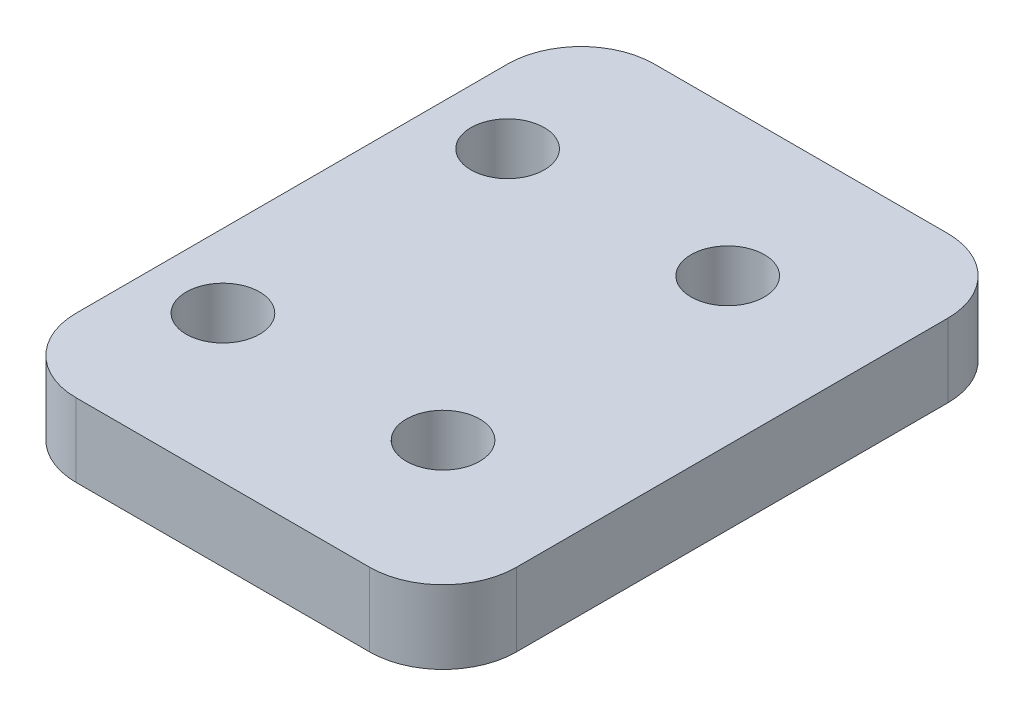
from build123d import *

# Parameters (mm, degrees)
SKETCH1_W           = 38.1
SKETCH1_H           = 50.038
SKETCH1_R           = 3.175
BOSS_EXTRUDE1_DEPTH = 6.35
FILLET1_R           = 6.35


with BuildPart() as part:
    # Sketch1 → Boss-Extrude1 (new body)
    with BuildSketch(Plane(origin=(0, 0, 0), x_dir=(1, 0, 0), z_dir=(0, 1, 0))):
        Rectangle(SKETCH1_W, SKETCH1_H)
        with Locations((6.35, -12.319)):
            Circle(SKETCH1_R, mode=Mode.SUBTRACT)
        with Locations((-12.7, -12.319)):
            Circle(SKETCH1_R, mode=Mode.SUBTRACT)
        with Locations((-12.7, 12.319)):
            Circle(SKETCH1_R, mode=Mode.SUBTRACT)
        with Locations((6.35, 12.319)):
            Circle(SKETCH1_R, mode=Mode.SUBTRACT)
    extrude(amount=BOSS_EXTRUDE1_DEPTH)

    # Fillet1
    fillet1_edges = [part.edges().sort_by_distance(p)[0] for p in [
        (19.05, 3.175, 25.019),
        (-19.05, 3.175, 25.019),
        (-19.05, 3.175, -25.019),
        (19.05, 3.175, -25.019),
    ]]
    fillet(fillet1_edges, radius=FILLET1_R)


solid = part.part
